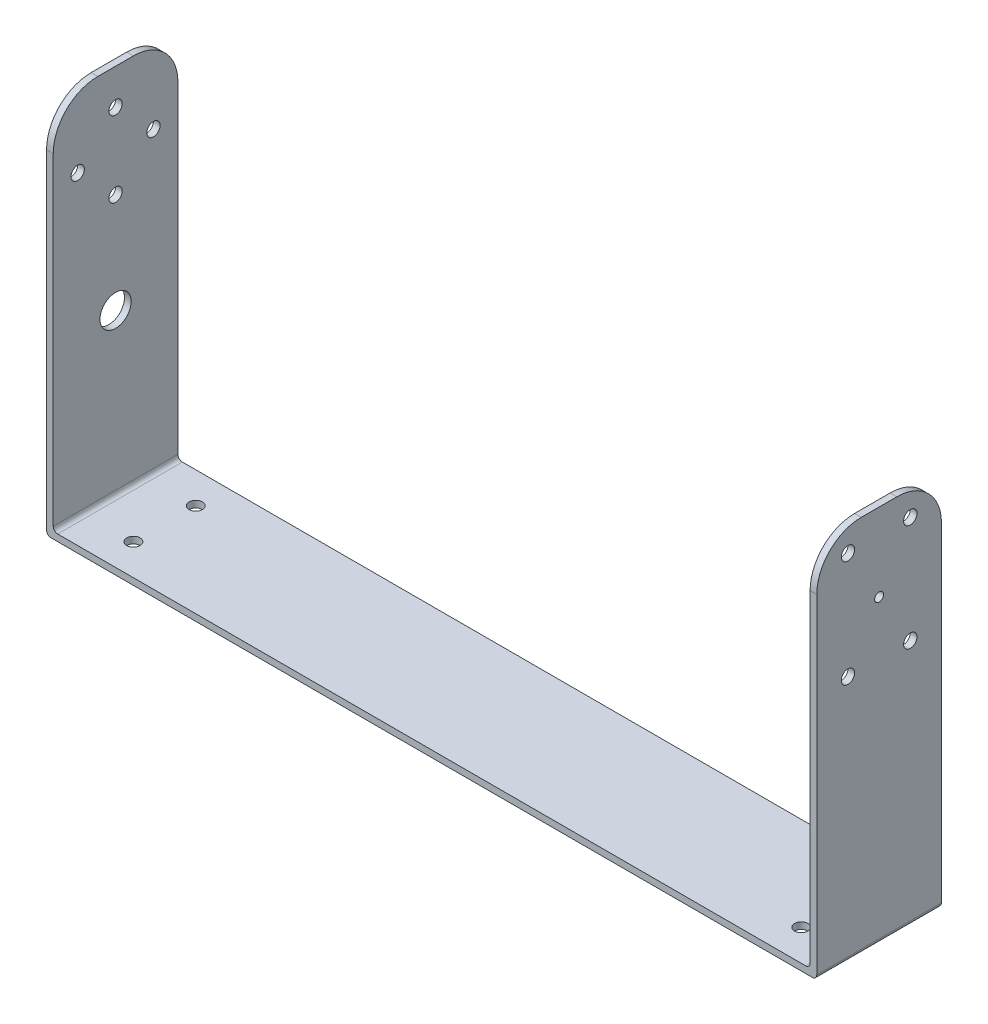
from build123d import *

# Parameters (mm, degrees)
SKETCH1_W               = 170
SKETCH1_H               = 28
BOSS_EXTRUDE1_DEPTH     = 1.5
SKETCH2_W               = 28
SKETCH2_H               = 85
BOSS_EXTRUDE2_DEPTH     = 1.5
FILLET2_R               = 10
FILLET3_R               = 1
FILLET4_R               = 1
SKETCH5_R               = 1.5
CUT_EXTRUDE2_DEPTH      = 15
CUT_EXTRUDE2_DEPTH_BACK = 15
SKETCH7_R               = 3.5
CUT_EXTRUDE3_DEPTH      = 15
CUT_EXTRUDE3_DEPTH_BACK = 15
SKETCH8_R               = 1.5
CUT_EXTRUDE4_DEPTH      = 15
CUT_EXTRUDE4_DEPTH_BACK = 15
SKETCH11_W              = 28
SKETCH11_H              = 85
SKETCH11_R              = 1
BOSS_EXTRUDE5_DEPTH     = 1.5
FILLET5_R               = 1
FILLET6_R               = 1
FILLET7_R               = 10
FILLET8_R               = 10
SKETCH12_R              = 1.5
CUT_EXTRUDE5_DEPTH      = 10
CUT_EXTRUDE5_DEPTH_BACK = 10


with BuildPart() as part:
    # Sketch1 → Boss-Extrude1 (new body)
    with BuildSketch(Plane(origin=(0, 0, 0), x_dir=(1, 0, 0), z_dir=(0, 1, 0))):
        with Locations((85, 14)):
            Rectangle(SKETCH1_W, SKETCH1_H)
    extrude(amount=BOSS_EXTRUDE1_DEPTH)

    # Sketch2 → Boss-Extrude2 (add)
    with BuildSketch(Plane(origin=(0, 0, 0), x_dir=(0, 0, -1), z_dir=(1, 0, 0))):
        with Locations((14, 42.5)):
            Rectangle(SKETCH2_W, SKETCH2_H)
    extrude(amount=-BOSS_EXTRUDE2_DEPTH)

    # Fillet2
    fillet2_edges = [part.edges().sort_by_distance(p)[0] for p in [
        (-0.75, 85, -28),
        (-0.75, 85, 0),
    ]]
    fillet(fillet2_edges, radius=FILLET2_R)

    # Fillet3
    fillet3_edges = [part.edges().sort_by_distance(p)[0] for p in [
        (-1.5, 0, -14),
    ]]
    fillet(fillet3_edges, radius=FILLET3_R)

    # Fillet4
    fillet4_edges = [part.edges().sort_by_distance(p)[0] for p in [
        (0, 1.5, -14),
    ]]
    fillet(fillet4_edges, radius=FILLET4_R)

    # Sketch5 → Cut-Extrude2 (cut, two sides)
    with BuildSketch(Plane(origin=(0, 0, 0), x_dir=(0, 0, -1), z_dir=(1, 0, 0))) as cut_extrude2_sk:
        with Locations((14, 77)):
            Circle(SKETCH5_R)
        with Locations((14, 60)):
            Circle(SKETCH5_R)
        with Locations((22.5, 68.5)):
            Circle(SKETCH5_R)
        with Locations((5.5, 68.5)):
            Circle(SKETCH5_R)
    extrude(amount=CUT_EXTRUDE2_DEPTH, mode=Mode.SUBTRACT)
    extrude(cut_extrude2_sk.sketch, amount=-CUT_EXTRUDE2_DEPTH_BACK, mode=Mode.SUBTRACT)

    # Sketch7 → Cut-Extrude3 (cut, two sides)
    with BuildSketch(Plane(origin=(0, 0, 0), x_dir=(0, 0, -1), z_dir=(1, 0, 0))) as cut_extrude3_sk:
        with Locations((14, 37.5)):
            Circle(SKETCH7_R)
    extrude(amount=CUT_EXTRUDE3_DEPTH, mode=Mode.SUBTRACT)
    extrude(cut_extrude3_sk.sketch, amount=-CUT_EXTRUDE3_DEPTH_BACK, mode=Mode.SUBTRACT)

    # Sketch8 → Cut-Extrude4 (cut, two sides)
    with BuildSketch(Plane(origin=(0, 1.5, 0), x_dir=(1, 0, 0), z_dir=(0, 1, 0))) as cut_extrude4_sk:
        with Locations((161, 7)):
            Circle(SKETCH8_R)
        with Locations((11, 21)):
            Circle(SKETCH8_R)
        with Locations((11, 7)):
            Circle(SKETCH8_R)
        with Locations((161, 21)):
            Circle(SKETCH8_R)
    extrude(amount=CUT_EXTRUDE4_DEPTH, mode=Mode.SUBTRACT)
    extrude(cut_extrude4_sk.sketch, amount=-CUT_EXTRUDE4_DEPTH_BACK, mode=Mode.SUBTRACT)

    # Sketch11 → Boss-Extrude5 (add)
    with BuildSketch(Plane(origin=(170, 0, 0), x_dir=(0, 0, -1), z_dir=(1, 0, 0))):
        with Locations((14, 42.5)):
            Rectangle(SKETCH11_W, SKETCH11_H)
        with Locations((14, 67.5)):
            Circle(SKETCH11_R, mode=Mode.SUBTRACT)
    extrude(amount=BOSS_EXTRUDE5_DEPTH)

    # Fillet5
    fillet5_edges = [part.edges().sort_by_distance(p)[0] for p in [
        (170, 1.5, -14),
    ]]
    fillet(fillet5_edges, radius=FILLET5_R)

    # Fillet6
    fillet6_edges = [part.edges().sort_by_distance(p)[0] for p in [
        (171.5, 0, -14),
    ]]
    fillet(fillet6_edges, radius=FILLET6_R)

    # Fillet7
    fillet7_edges = [part.edges().sort_by_distance(p)[0] for p in [
        (170.75, 85, 0),
    ]]
    fillet(fillet7_edges, radius=FILLET7_R)

    # Fillet8
    fillet8_edges = [part.edges().sort_by_distance(p)[0] for p in [
        (170.75, 85, -28),
    ]]
    fillet(fillet8_edges, radius=FILLET8_R)

    # Sketch12 → Cut-Extrude5 (cut, two sides)
    with BuildSketch(Plane.ZY.offset(-170)) as cut_extrude5_sk:
        with Locations((-21, 79.5)):
            Circle(SKETCH12_R)
        with Locations((-7, 79.5)):
            Circle(SKETCH12_R)
        with Locations((-7, 55.5)):
            Circle(SKETCH12_R)
        with Locations((-21, 55.5)):
            Circle(SKETCH12_R)
    extrude(amount=CUT_EXTRUDE5_DEPTH, mode=Mode.SUBTRACT)
    extrude(cut_extrude5_sk.sketch, amount=-CUT_EXTRUDE5_DEPTH_BACK, mode=Mode.SUBTRACT)


solid = part.part
